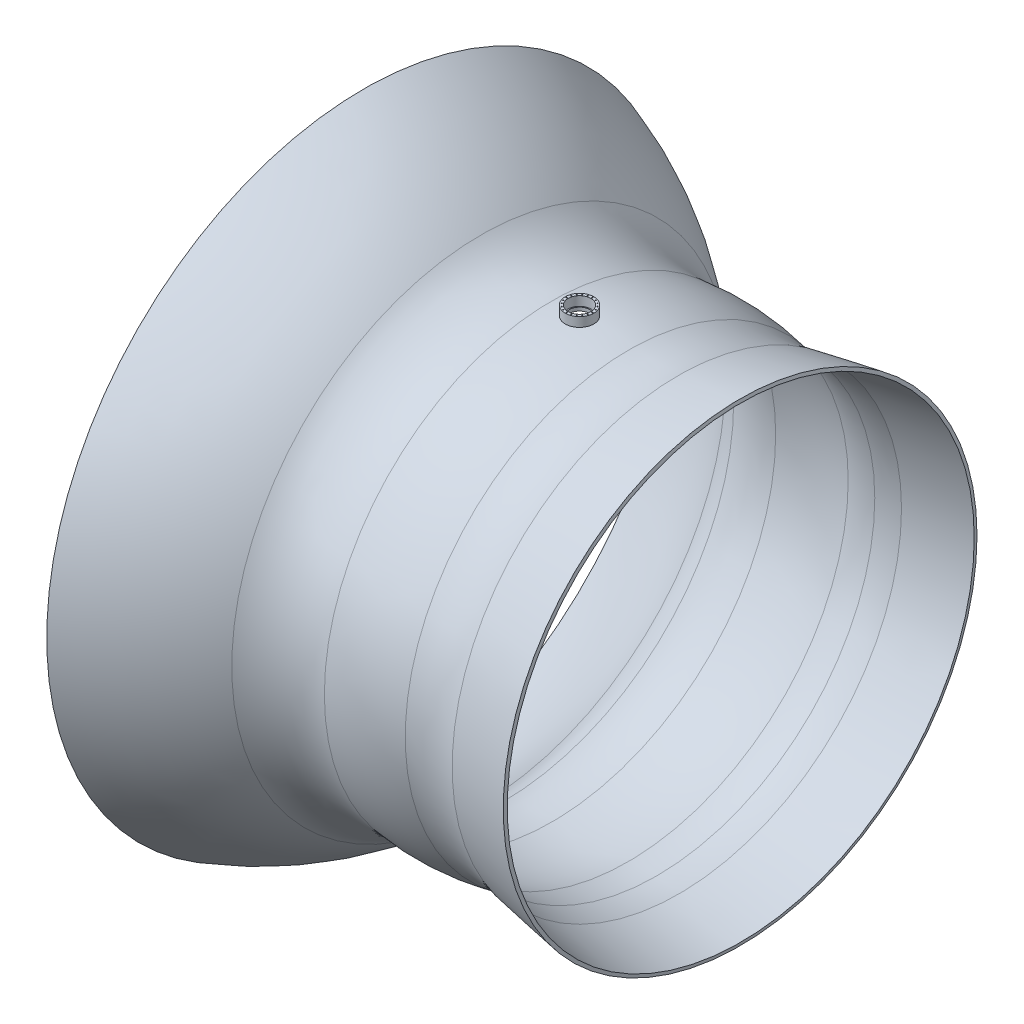
from build123d import *

# Parameters (mm, degrees)
ESBO_O2_R                                     = 180
CORTE_EXTRUS_O1_DEPTH                         = 5553.983707
RESSALTO_EXTRUS_O1_START                      = 4002.199395
ESBO_O3_R                                     = 250
ESBO_O3_R_2                                   = 200
RESSALTO_EXTRUS_O1_DEPTH                      = 163.800605
BROCA_DE_ROSQUEAR_PARA_TARRAXA_DE_M20X2_D     = 18
BROCA_DE_ROSQUEAR_PARA_TARRAXA_DE_M20X2_DEPTH = 52
BROCA_DE_ROSQUEAR_PARA_TARRAXA_DE_M20X2_TIP   = 5.407746


with BuildPart() as part:
    # Esboço1 → Revolução1 (revolve)
    with BuildSketch(Plane.XY):
        with BuildLine():
            Line((2824, 4091), (1741, 3900))
            ThreePointArc((1741, 3900), (1298.08634, 3819.525517), (849.53115, 3857.563587))
            ThreePointArc((849.53115, 3857.563587), (185.733379, 3945.630889), (-483.401983, 3920.308983))
            ThreePointArc((-483.401983, 3920.308983), (-1168.198907, 3982.262559), (-1766.251185, 4321.553799))
            ThreePointArc((-1766.251185, 4321.553799), (-2722.644619, 5013.509757), (-3800, 5496))
            Line((-3800, 5496), (-3781.215507, 5552.983707))
            ThreePointArc((-3781.215507, 5552.983707), (-2692.639623, 5065.468396), (-1726.285486, 4366.305814))
            ThreePointArc((-1726.285486, 4366.305814), (-1150.287994, 4039.526852), (-490.744798, 3979.85798))
            ThreePointArc((-490.744798, 3979.85798), (188.554645, 4005.564523), (862.435421, 3916.159489))
            ThreePointArc((862.435421, 3916.159489), (1297.27589, 3879.55615), (1726.478878, 3958.364988))
            Line((1726.478878, 3958.364988), (2813.579105, 4150.088112))
            Line((2813.579105, 4150.088112), (2824, 4091))
        make_face()
    revolve(axis=Axis((0, 0, 0), (1, 0, 0)))

    # Esboço2 → Corte-extrusão1 (cut, through all)
    with BuildSketch(Plane(origin=(0, 0, 0), x_dir=(1, 0, 0), z_dir=(0, 1, 0))):
        Circle(ESBO_O2_R)
    extrude(amount=CORTE_EXTRUS_O1_DEPTH, mode=Mode.SUBTRACT)

    # Esboço3 → Ressalto-extrusão1 (add)
    with BuildSketch(Plane(origin=(0, 0, 0), x_dir=(1, 0, 0), z_dir=(0, 1, 0)).offset(RESSALTO_EXTRUS_O1_START)):
        Circle(ESBO_O3_R)
        Circle(ESBO_O3_R_2, mode=Mode.SUBTRACT)
    extrude(amount=RESSALTO_EXTRUS_O1_DEPTH)

    # Broca de rosquear para tarraxa de M20x2.01
    with Locations(Plane(origin=(0, 4166, 0), x_dir=(1, 0, 0), z_dir=(0, 1, 0))):
        with Locations((0, 225), (69.528824, 213.987716), (132.251682, 182.028824), (182.028824, 132.251682), (213.987716, 69.528824), (225, 0), (213.987716, -69.528824), (182.028824, -132.251682), (132.251682, -182.028824), (69.528824, -213.987716), (0, -225), (-69.528824, -213.987716), (-132.251682, -182.028824), (-182.028824, -132.251682), (-213.987716, -69.528824), (-225, 0), (-213.987716, 69.528824), (-182.028824, 132.251682), (-132.251682, 182.028824), (-69.528824, 213.987716), (0, 0)):
            Hole(BROCA_DE_ROSQUEAR_PARA_TARRAXA_DE_M20X2_D / 2, depth=BROCA_DE_ROSQUEAR_PARA_TARRAXA_DE_M20X2_DEPTH)
            with Locations((0, 0, -(BROCA_DE_ROSQUEAR_PARA_TARRAXA_DE_M20X2_DEPTH + BROCA_DE_ROSQUEAR_PARA_TARRAXA_DE_M20X2_TIP / 2))):  # 118° drill point
                Cone(0, BROCA_DE_ROSQUEAR_PARA_TARRAXA_DE_M20X2_D / 2, BROCA_DE_ROSQUEAR_PARA_TARRAXA_DE_M20X2_TIP, mode=Mode.SUBTRACT)


solid = part.part
